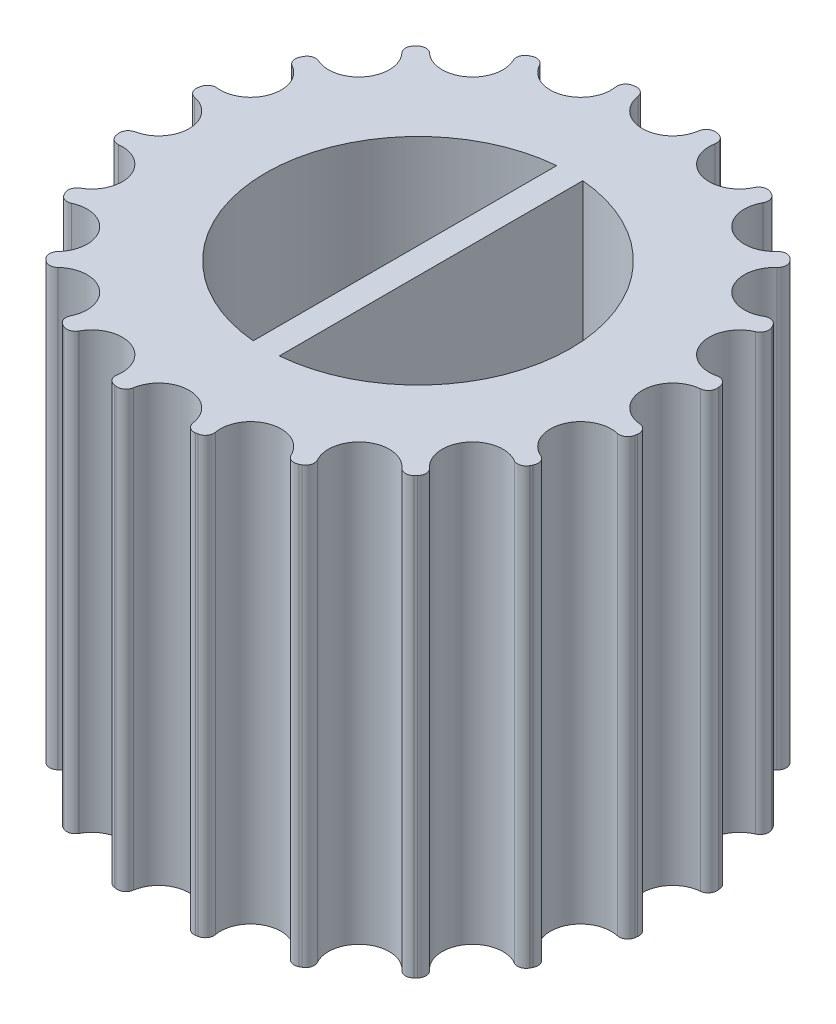
from build123d import *

# Parameters (mm, degrees)
BOSS_EXTRUDE1_DEPTH = 10
SKETCH2_R           = 0.7
CUT_EXTRUDE1_DEPTH  = 10
CIRPATTERN3_COUNT   = 20
FILLET1_R           = 0.2
CUT_EXTRUDE2_REACH  = 12
SKETCH3_R           = 3.5
SKETCH4_W           = 0.6
SKETCH4_H           = 10.414964042
BOSS_EXTRUDE2_DEPTH = 10


with BuildPart() as part:
    # Sketch1 → Boss-Extrude1 (new body)
    with BuildSketch(Plane(origin=(0, 0, 0), x_dir=(1, 0, 0), z_dir=(0, 1, 0))):
        Polygon((4.951468525, -3.59745246), (5.820800352, -1.891292682), (6.120351685, 0), (5.820800352, 1.891292682), (4.951468525, 3.59745246), (3.59745246, 4.951468525), (1.891292682, 5.820800352), (0, 6.120351685), (-1.891292682, 5.820800352), (-3.59745246, 4.951468525), (-4.951468525, 3.59745246), (-5.820800352, 1.891292682), (-6.120351685, 0), (-5.820800352, -1.891292682), (-4.951468525, -3.59745246), (-3.59745246, -4.951468525), (-1.891292682, -5.820800352), (0, -6.120351685), (1.891292682, -5.820800352), (3.59745246, -4.951468525), align=None)
    extrude(amount=BOSS_EXTRUDE1_DEPTH)

    # Sketch2 → Cut-Extrude1 (cut)
    with BuildSketch(Plane(origin=(0, 10, 0), x_dir=(1, 0, 0), z_dir=(0, 1, 0))):
        with Locations((5.855, 0)):
            Circle(SKETCH2_R)
    cut_extrude1 = extrude(amount=-CUT_EXTRUDE1_DEPTH, mode=Mode.SUBTRACT)

    # CirPattern3: Cut-Extrude1 ×20 about axis
    cirpattern3_axis = Axis((-0.052482021, 0, 0), (0, 1, 0))
    for i in range(1, CIRPATTERN3_COUNT):
        add(cut_extrude1.rotate(cirpattern3_axis, i * 360 / CIRPATTERN3_COUNT), mode=Mode.SUBTRACT)

    # Fillet1
    fillet1_edges = [part.edges().sort_by_distance(p)[0] for p in [
        (4.057798917, 5, -4.491122068),
        (2.93831654, 5, -5.287315051),
        (5.251367741, 5, -3.008867108),
        (4.438640047, 5, -4.110280937),
        (2.467098423, 5, -5.527412673),
        (1.150354408, 5, -5.938153446),
        (0.638542887, 5, -6.019216428),
        (-0.746045616, 5, -6.002189668),
        (-1.247642454, 5, -5.922744534),
        (-2.563808053, 5, -5.478136656),
        (-3.008267267, 5, -5.251673375),
        (-4.126835407, 5, -4.422085577),
        (-4.474567598, 5, -4.074353387),
        (-5.286407893, 5, -2.940096937),
        (-5.507494847, 5, -2.506189359),
        (-5.933957193, 5, -1.176848512),
        (-6.009763498, 5, -0.698226334),
        (-6.009763498, 5, 0.698226334),
        (-5.933957193, 5, 1.176848512),
        (-5.507494847, 5, 2.506189359),
        (-5.286407893, 5, 2.940096937),
        (-4.474567598, 5, 4.074353387),
        (-4.126835407, 5, 4.422085577),
        (-3.008267267, 5, 5.251673375),
        (-2.563808053, 5, 5.478136656),
        (-1.247642454, 5, 5.922744534),
        (-0.746045616, 5, 6.002189668),
        (0.638542887, 5, 6.019216428),
        (1.150354408, 5, 5.938153446),
        (2.467098423, 5, 5.527412673),
        (2.93831654, 5, 5.287315051),
        (4.057798917, 5, 4.491122068),
        (5.251367741, 5, 3.008867108),
        (4.438640047, 5, 4.110280937),
        (5.499267273, 5, 2.522336881),
        (5.926264611, 5, 1.225417561),
        (5.926264611, 5, -1.225417561),
        (5.499267273, 5, -2.522336881),
        (6.012318774, 5, 0.682092958),
        (6.012318774, 5, -0.682092958),
    ]]
    fillet(fillet1_edges, radius=FILLET1_R)

    # Sketch3 → Cut-Extrude2 (cut, up to next)
    with BuildSketch(Plane(origin=(0, 10, 0), x_dir=(1, 0, 0), z_dir=(0, 1, 0)), mode=Mode.PRIVATE) as cut_extrude2_sk1:
        with Locations(Location((0, 0, 0), (0, 0, 270))):  # turned: the seam where the file's is
            Circle(SKETCH3_R)
    cut_extrude2_tool1 = extrude(cut_extrude2_sk1.sketch, amount=-CUT_EXTRUDE2_REACH, mode=Mode.PRIVATE) & part.part
    add(cut_extrude2_tool1.solids().sort_by_distance((0, 10, 0))[0], mode=Mode.SUBTRACT)

    # Sketch4 → Boss-Extrude2 (add)
    with BuildSketch(Plane.XZ):
        Rectangle(SKETCH4_W, SKETCH4_H)
    extrude(amount=-BOSS_EXTRUDE2_DEPTH)


solid = part.part
